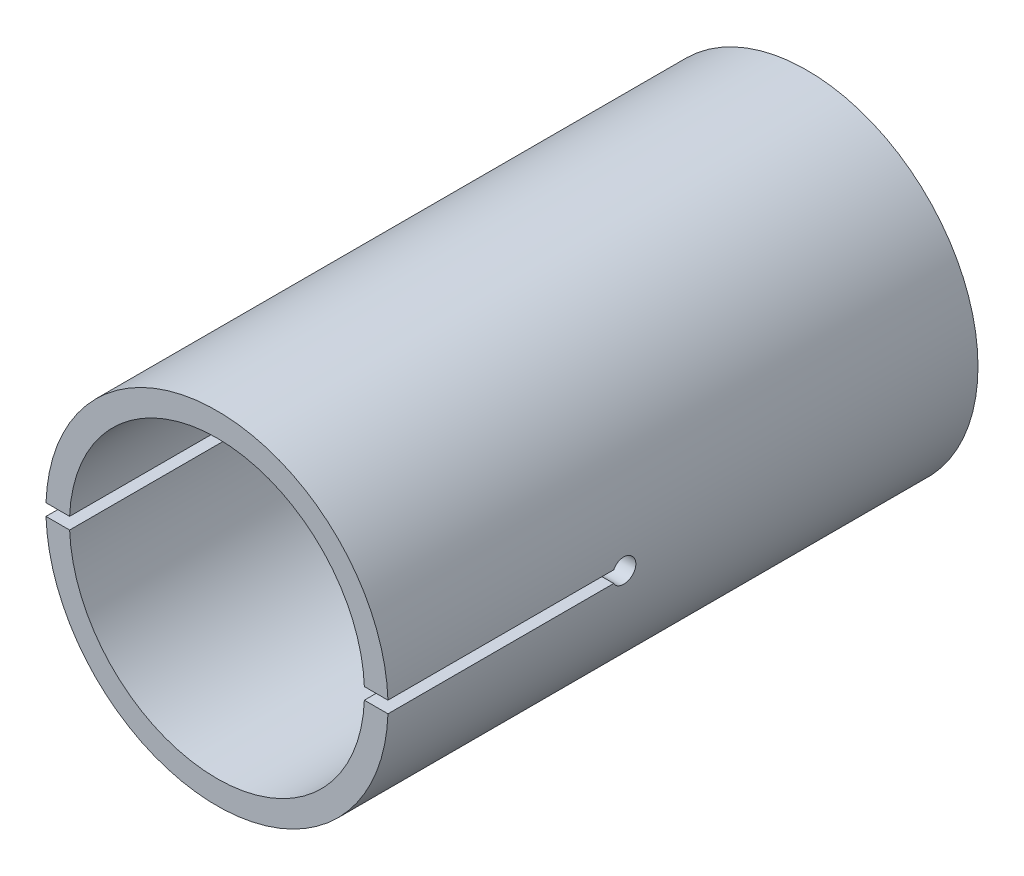
from build123d import *

# Parameters (mm, degrees)
SKIZZE1_R                              = 14.5
AUFSATZ_LINEAR_AUSTRAGEN1_DEPTH        = 50
SKIZZE5_W                              = 3.2
SKIZZE5_H                              = 2
SCHNITT_LINEAR_AUSTRAGEN1_DEPTH        = 25
F_24_5_24_5_DURCHMESSER_BOHRUNG1_D     = 12.5
F_24_5_24_5_DURCHMESSER_BOHRUNG2_D     = 25
F_24_5_24_5_DURCHMESSER_BOHRUNG2_DEPTH = 30
F_24_5_24_5_DURCHMESSER_BOHRUNG2_TIP   = 7.510757738
SCHNITT_LINEAR_AUSTRAGEN2_DEPTH        = 20
F_2_0_2_DURCHMESSER_BOHRUNG11_D        = 2
F_2_0_2_DURCHMESSER_BOHRUNG11_DEPTH    = 30
F_2_0_2_DURCHMESSER_BOHRUNG11_TIP      = 0.600860619


with BuildPart() as part:
    # Skizze1 → Aufsatz-Linear austragen1 (new body)
    with BuildSketch(Plane.XY):
        Circle(SKIZZE1_R)
    extrude(amount=AUFSATZ_LINEAR_AUSTRAGEN1_DEPTH)

    # Skizze5 → Schnitt-Linear austragen1 (cut)
    with BuildSketch(Plane(origin=(0, 0, 0), x_dir=(-1, 0, 0), z_dir=(0, 0, -1))):
        with Locations((0, 6.8)):
            Rectangle(SKIZZE5_W, SKIZZE5_H)
    extrude(amount=-SCHNITT_LINEAR_AUSTRAGEN1_DEPTH, mode=Mode.SUBTRACT)

    # Ø24.5 (24.5) Durchmesser Bohrung1 (through all)
    with Locations(Plane(origin=(0, 0, 0), x_dir=(-1, 0, 0), z_dir=(0, 0, -1))):
        with Locations((0, 0)):
            Hole(F_24_5_24_5_DURCHMESSER_BOHRUNG1_D / 2)

    # Ø24.5 (24.5) Durchmesser Bohrung2
    with Locations(Plane.XY.offset(50)):
        with Locations((0, 0)):
            Hole(F_24_5_24_5_DURCHMESSER_BOHRUNG2_D / 2, depth=F_24_5_24_5_DURCHMESSER_BOHRUNG2_DEPTH)
            with Locations((0, 0, -(F_24_5_24_5_DURCHMESSER_BOHRUNG2_DEPTH + F_24_5_24_5_DURCHMESSER_BOHRUNG2_TIP / 2))):  # 118° drill point
                Cone(0, F_24_5_24_5_DURCHMESSER_BOHRUNG2_D / 2, F_24_5_24_5_DURCHMESSER_BOHRUNG2_TIP, mode=Mode.SUBTRACT)

    # Skizze12 → Schnitt-Linear austragen2 (cut)
    with BuildSketch(Plane.XY.offset(50)):
        with BuildLine():
            Line((-14.491376746, 0.5), (-12.489995997, 0.5))
            ThreePointArc((-12.489995997, 0.5), (-12.5, 0), (-12.489995997, -0.5))
            Line((-12.489995997, -0.5), (-14.491376746, -0.5))
            ThreePointArc((-14.491376746, -0.5), (-14.5, 0), (-14.491376746, 0.5))
        make_face()
        with BuildLine():
            Line((12.489995997, 0.5), (14.491376746, 0.5))
            ThreePointArc((14.491376746, 0.5), (14.5, 0), (14.491376746, -0.5))
            Line((14.491376746, -0.5), (12.489995997, -0.5))
            ThreePointArc((12.489995997, -0.5), (12.5, 0), (12.489995997, 0.5))
        make_face()
    extrude(amount=-SCHNITT_LINEAR_AUSTRAGEN2_DEPTH, mode=Mode.SUBTRACT)

    # Ø2.0 (2) Durchmesser Bohrung11
    with Locations(Plane(origin=(-14.5, 0, 30), x_dir=(0, 0, 1), z_dir=(-1, 0, 0))):
        with Locations((0, 0)):
            Hole(F_2_0_2_DURCHMESSER_BOHRUNG11_D / 2, depth=F_2_0_2_DURCHMESSER_BOHRUNG11_DEPTH)
            with Locations((0, 0, -(F_2_0_2_DURCHMESSER_BOHRUNG11_DEPTH + F_2_0_2_DURCHMESSER_BOHRUNG11_TIP / 2))):  # 118° drill point
                Cone(0, F_2_0_2_DURCHMESSER_BOHRUNG11_D / 2, F_2_0_2_DURCHMESSER_BOHRUNG11_TIP, mode=Mode.SUBTRACT)


solid = part.part
